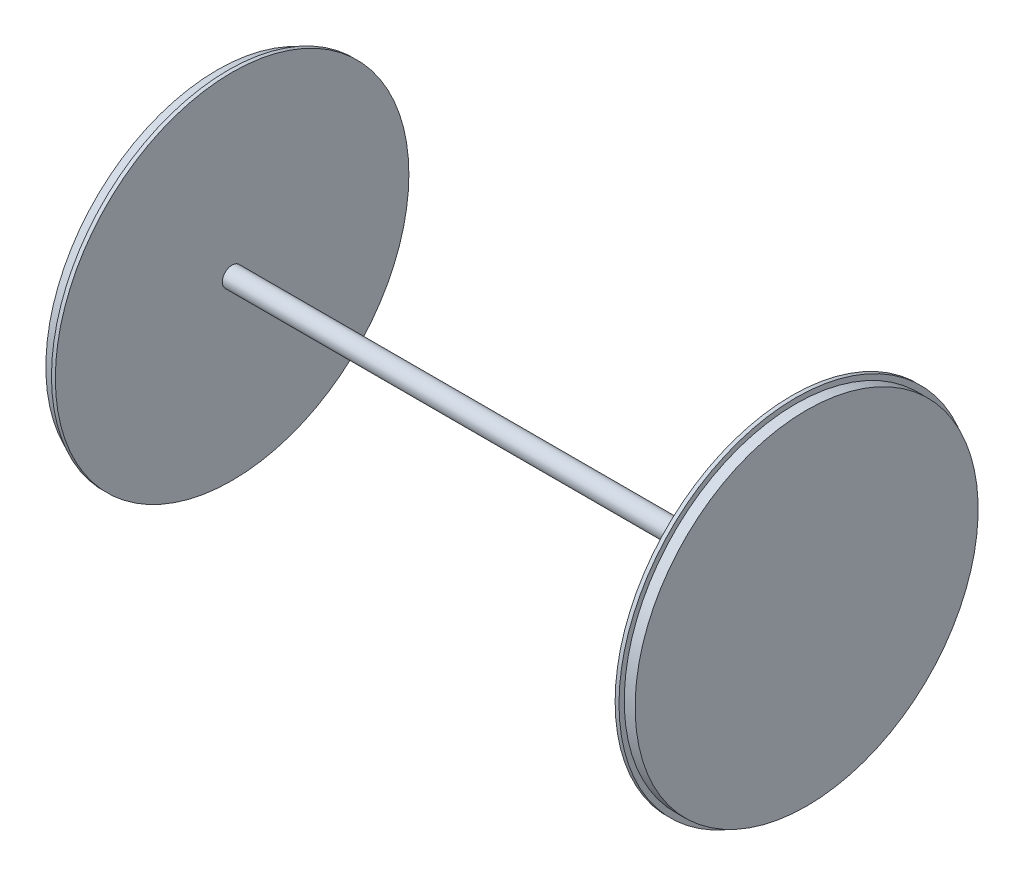
from build123d import *


with BuildPart() as part:
    # Sketch1 → Revolve2 (revolve)
    with BuildSketch(Plane.XY):
        Polygon((0, 0), (-3048, 0), (-3048, 887.22), (-2991.8, 887.22), (-2991.8, 914.4), (-2971.8, 914.4), (-2971.8, 50.8), (-76.2, 50.8), (-76.2, 914.4), (-56.2, 914.4), (-56.2, 887.22), (0, 887.22), align=None)
    revolve(axis=Axis((0, 0, 0), (-1, 0, 0)))


solid = part.part
